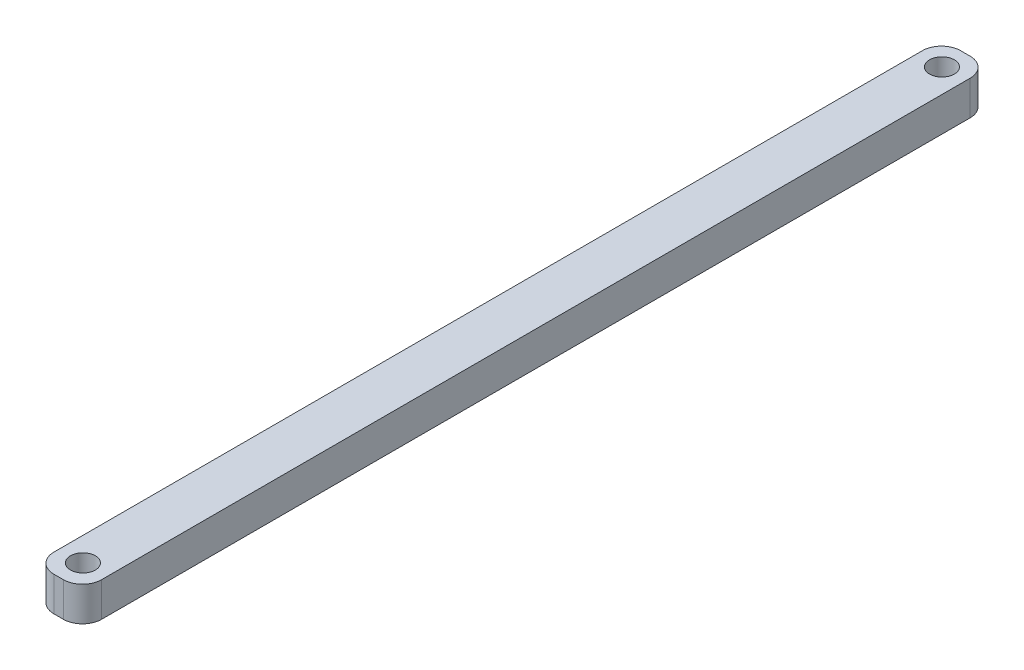
from build123d import *

# Parameters (mm, degrees)
SKETCH1_W           = 6.35
SKETCH1_H           = 120.65
EXTRUDE_THIN1_DEPTH = 4.572
SKETCH2_R           = 1.651
CUT_EXTRUDE1_DEPTH  = 4.572
LPATTERN1_COUNT     = 6
LPATTERN1_PITCH     = 114.3
FILLET1_R           = 2.54


with BuildPart() as part:
    # Sketch1 → Extrude-Thin1 (new body)
    with BuildSketch(Plane(origin=(0, 0, 0), x_dir=(1, 0, 0), z_dir=(0, 1, 0))):
        with Locations((-3.175, -29.775350058)):
            Rectangle(SKETCH1_W, SKETCH1_H)
    extrude(amount=EXTRUDE_THIN1_DEPTH)

    # Sketch2 → Cut-Extrude1 (cut)
    with BuildSketch(Plane(origin=(0, 4.572, 0), x_dir=(1, 0, 0), z_dir=(0, 1, 0))):
        with Locations((-3.175, 27.432)):
            Circle(SKETCH2_R)
    cut_extrude1 = extrude(amount=-CUT_EXTRUDE1_DEPTH, mode=Mode.SUBTRACT)

    # LPattern1: Cut-Extrude1 ×6
    with Locations(*[(0, 0, i * LPATTERN1_PITCH) for i in range(1, LPATTERN1_COUNT)]):
        add(cut_extrude1, mode=Mode.SUBTRACT)

    # Fillet1
    fillet1_edges = [part.edges().sort_by_distance(p)[0] for p in [
        (-6.35, 2.286, -30.549649942),
        (0, 2.286, -30.549649942),
        (0, 2.286, 90.100350058),
        (-6.35, 2.286, 90.100350058),
    ]]
    fillet(fillet1_edges, radius=FILLET1_R)


solid = part.part
